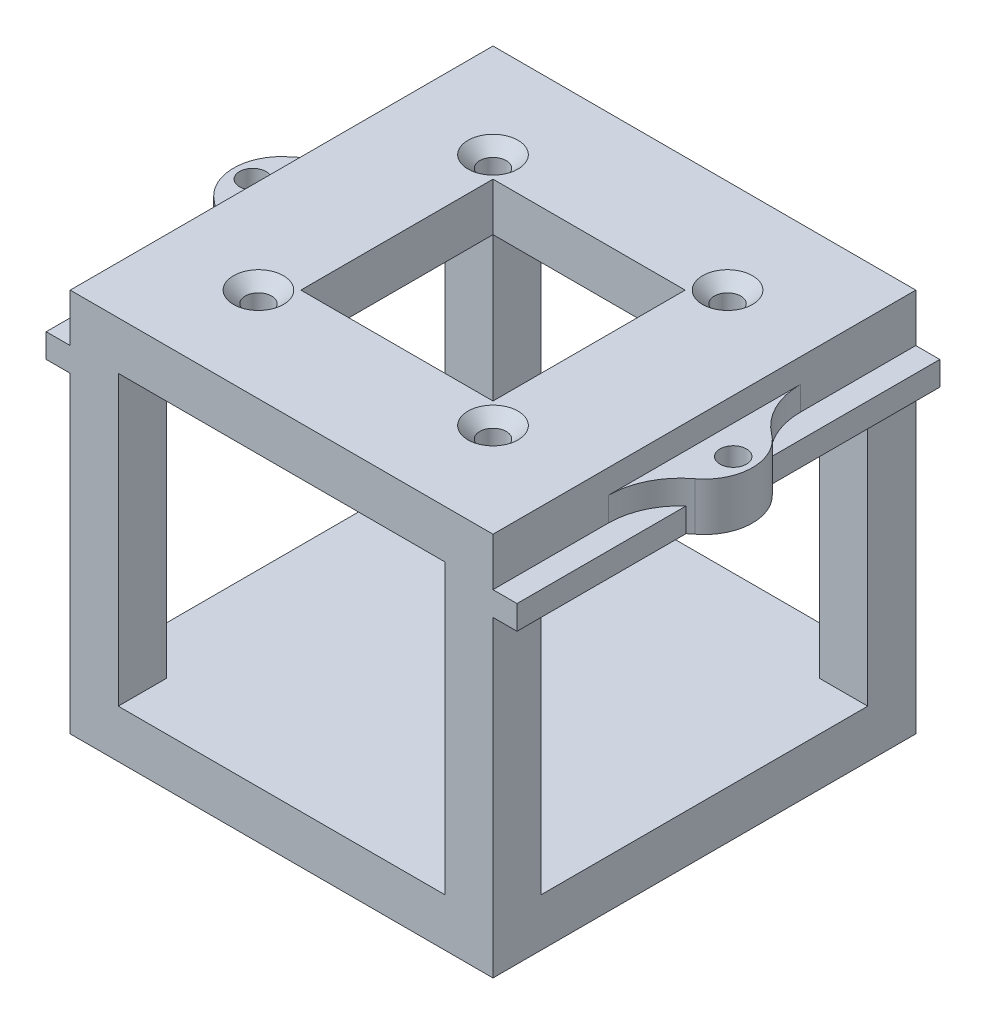
from build123d import *

# Parameters (mm, degrees)
SKETCH1_W                = 55.88
SKETCH1_H                = 55.88
BOSS_EXTRUDE1_DEPTH      = 50.8
SKETCH2_W                = 43.18
SKETCH2_H                = 38.1
CUT_EXTRUDE1_DEPTH       = 56.88
SKETCH3_W                = 43.18
SKETCH3_H                = 38.1
CUT_EXTRUDE2_DEPTH       = 56.88
SKETCH4_R                = 1.75
SKETCH4_W                = 25.4
SKETCH4_H                = 25.4
CUT_EXTRUDE3_DEPTH       = 44.45
BOSS_EXTRUDE2_DEPTH      = 3.175
BOSS_EXTRUDE2_DEPTH_BACK = 3.175
SKETCH10_W               = 9.525
SKETCH10_H               = 3.175
BOSS_EXTRUDE5_DEPTH      = 55.88
SKETCH11_R               = 1.75
CUT_EXTRUDE4_DEPTH       = 48.625


with BuildPart() as part:
    # Sketch1 → Boss-Extrude1 (new body)
    with BuildSketch(Plane(origin=(0, 0, 0), x_dir=(1, 0, 0), z_dir=(0, 1, 0))):
        with Locations((27.94, 27.94)):
            Rectangle(SKETCH1_W, SKETCH1_H)
    extrude(amount=BOSS_EXTRUDE1_DEPTH)

    # Sketch2 → Cut-Extrude1 (cut, through all)
    with BuildSketch(Plane.XY):
        with Locations((27.94, 25.4)):
            Rectangle(SKETCH2_W, SKETCH2_H)
    extrude(amount=-CUT_EXTRUDE1_DEPTH, mode=Mode.SUBTRACT)

    # Sketch3 → Cut-Extrude2 (cut, through all)
    with BuildSketch(Plane(origin=(55.88, 0, 0), x_dir=(0, 0, -1), z_dir=(1, 0, 0))):
        with Locations((27.94, 25.4)):
            Rectangle(SKETCH3_W, SKETCH3_H)
    extrude(amount=-CUT_EXTRUDE2_DEPTH, mode=Mode.SUBTRACT)

    # Sketch4 → Cut-Extrude3 (cut)
    with BuildSketch(Plane(origin=(0, 50.8, 0), x_dir=(1, 0, 0), z_dir=(0, 1, 0))):
        with Locations((43.44, 43.44)):
            Circle(SKETCH4_R)
        with Locations((43.44, 12.44)):
            Circle(SKETCH4_R)
        with Locations((12.44, 12.44)):
            Circle(SKETCH4_R)
        with Locations((12.44, 43.44)):
            Circle(SKETCH4_R)
        with Locations((27.94, 27.94)):
            Rectangle(SKETCH4_W, SKETCH4_H)
    extrude(amount=-CUT_EXTRUDE3_DEPTH, mode=Mode.SUBTRACT)

    # Sketch5 → Cut-Revolve1 (revolve, cut)
    with BuildSketch(Plane(origin=(12.44, 0, 0), x_dir=(0, 0, -1), z_dir=(1, 0, 0))):
        Polygon((43.44, 50.8), (40.138, 50.8), (43.44, 47.498), align=None)
    revolve(axis=Axis((12.44, 47.498, -43.44), (0, 1, 0)), mode=Mode.SUBTRACT)

    # Sketch6 → Cut-Revolve2 (revolve, cut)
    with BuildSketch(Plane(origin=(12.44, 0, 0), x_dir=(0, 0, -1), z_dir=(1, 0, 0))):
        Polygon((12.44, 50.8), (9.138, 50.8), (12.44, 47.498), align=None)
    revolve(axis=Axis((12.44, 47.498, -12.44), (0, 1, 0)), mode=Mode.SUBTRACT)

    # Sketch7 → Cut-Revolve3 (revolve, cut)
    with BuildSketch(Plane(origin=(43.44, 0, 0), x_dir=(0, 0, -1), z_dir=(1, 0, 0))):
        Polygon((43.44, 50.8), (40.138, 50.8), (43.44, 47.498), align=None)
    revolve(axis=Axis((43.44, 47.498, -43.44), (0, 1, 0)), mode=Mode.SUBTRACT)

    # Sketch8 → Cut-Revolve4 (revolve, cut)
    with BuildSketch(Plane(origin=(43.44, 0, 0), x_dir=(0, 0, -1), z_dir=(1, 0, 0))):
        Polygon((12.44, 50.8), (9.138, 50.8), (12.44, 47.498), align=None)
    revolve(axis=Axis((43.44, 47.498, -12.44), (0, 1, 0)), mode=Mode.SUBTRACT)

    # Sketch9 → Boss-Extrude2 (add, two sides)
    with BuildSketch(Plane.XZ.offset(-44.45)) as boss_extrude2_sk:
        with BuildLine():
            Line((0, -40.64), (0, -15.24))
            ThreePointArc((0, -15.24), (-1.005581006, -19.499709497), (-3.81, -22.86))
            ThreePointArc((-3.81, -22.86), (-6.35, -27.94), (-3.81, -33.02))
            ThreePointArc((-3.81, -33.02), (-1.005581006, -36.380290503), (0, -40.64))
        make_face()
        with BuildLine():
            Line((55.88, -40.64), (55.88, -15.24))
            ThreePointArc((55.88, -15.24), (56.885581006, -19.499709497), (59.69, -22.86))
            ThreePointArc((59.69, -22.86), (62.23, -27.94), (59.69, -33.02))
            ThreePointArc((59.69, -33.02), (56.885581006, -36.380290503), (55.88, -40.64))
        make_face()
    extrude(amount=BOSS_EXTRUDE2_DEPTH)
    extrude(boss_extrude2_sk.sketch, amount=-BOSS_EXTRUDE2_DEPTH_BACK)

    # Sketch10 → Boss-Extrude5 (add)
    with BuildSketch(Plane.XY):
        with Locations((54.2925, 42.8625)):
            Rectangle(SKETCH10_W, SKETCH10_H)
        with Locations((1.5875, 42.8625)):
            Rectangle(SKETCH10_W, SKETCH10_H)
    extrude(amount=-BOSS_EXTRUDE5_DEPTH)

    # Sketch11 → Cut-Extrude4 (cut, through all)
    with BuildSketch(Plane(origin=(0, 47.625, 0), x_dir=(1, 0, 0), z_dir=(0, 1, 0))):
        with Locations((-3.81, 27.94)):
            Circle(SKETCH11_R)
        with Locations((59.69, 27.94)):
            Circle(SKETCH11_R)
    extrude(amount=-CUT_EXTRUDE4_DEPTH, mode=Mode.SUBTRACT)


solid = part.part
